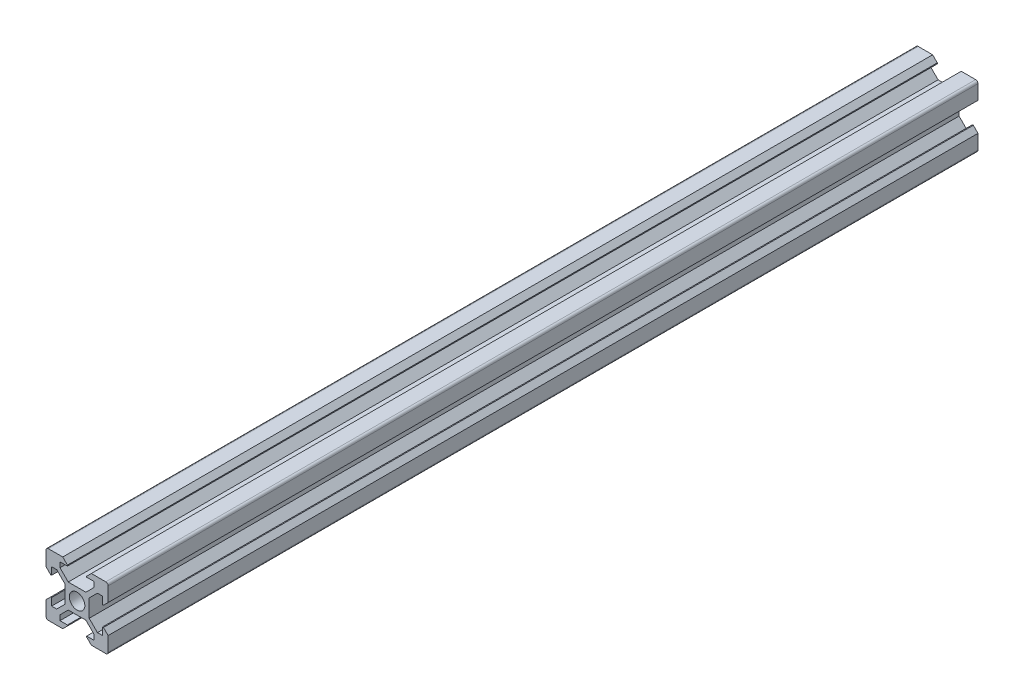
from build123d import *

# Parameters (mm, degrees)
CROQUIS1_R              = 2.5
SALIENTE_EXTRUIR1_DEPTH = 326
SKETCH2_W               = 139.582587955
SKETCH2_H               = 242.432915921
CUT_EXTRUDE1_DEPTH      = 47
CUT_EXTRUDE1_DEPTH_BACK = 30


with BuildPart() as part:
    # Croquis1 → Saliente-Extruir1 (new body)
    with BuildSketch(Plane.XY):
        with BuildLine():
            Line((-4.6, 10), (-3.1, 8.5))
            Line((-3.1, 8.5), (-3.1, 8.2))
            Line((-3.1, 8.2), (-5.5, 8.2))
            Line((-5.5, 8.2), (-5.5, 6.560660172))
            Line((-5.5, 6.560660172), (-2.84, 3.900660172))
            Line((-2.84, 3.900660172), (0, 3.900660172))
            Line((0, 3.900660172), (2.84, 3.900660172))
            Line((2.84, 3.900660172), (5.5, 6.560660172))
            Line((5.5, 6.560660172), (5.5, 8.2))
            Line((5.5, 8.2), (3.1, 8.2))
            Line((3.1, 8.2), (3.1, 8.5))
            Line((3.1, 8.5), (4.6, 10))
            Line((4.6, 10), (9.25, 10))
            ThreePointArc((9.25, 10), (9.780330086, 9.780330086), (10, 9.25))
            Line((10, 9.25), (10, 4.6))
            Line((10, 4.6), (8.5, 3.1))
            Line((8.5, 3.1), (8.2, 3.1))
            Line((8.2, 3.1), (8.2, 5.5))
            Line((8.2, 5.5), (6.560660172, 5.5))
            Line((6.560660172, 5.5), (3.900660172, 2.84))
            Line((3.900660172, 2.84), (3.900660172, 0))
            Line((3.900660172, 0), (3.900660172, -2.84))
            Line((3.900660172, -2.84), (6.560660172, -5.5))
            Line((6.560660172, -5.5), (8.2, -5.5))
            Line((8.2, -5.5), (8.2, -3.1))
            Line((8.2, -3.1), (8.5, -3.1))
            Line((8.5, -3.1), (10, -4.6))
            Line((10, -4.6), (10, -9.25))
            ThreePointArc((10, -9.25), (9.780330086, -9.780330086), (9.25, -10))
            Line((9.25, -10), (4.6, -10))
            Line((4.6, -10), (3.1, -8.5))
            Line((3.1, -8.5), (3.1, -8.2))
            Line((3.1, -8.2), (5.5, -8.2))
            Line((5.5, -8.2), (5.5, -6.560660172))
            Line((5.5, -6.560660172), (2.84, -3.900660172))
            Line((2.84, -3.900660172), (0, -3.900660172))
            Line((0, -3.900660172), (-2.84, -3.900660172))
            Line((-2.84, -3.900660172), (-5.5, -6.560660172))
            Line((-5.5, -6.560660172), (-5.5, -8.2))
            Line((-5.5, -8.2), (-3.1, -8.2))
            Line((-3.1, -8.2), (-3.1, -8.5))
            Line((-3.1, -8.5), (-4.6, -10))
            Line((-4.6, -10), (-9.25, -10))
            ThreePointArc((-9.25, -10), (-9.780330086, -9.780330086), (-10, -9.25))
            Line((-10, -9.25), (-10, -4.6))
            Line((-10, -4.6), (-8.5, -3.1))
            Line((-8.5, -3.1), (-8.2, -3.1))
            Line((-8.2, -3.1), (-8.2, -5.5))
            Line((-8.2, -5.5), (-6.560660172, -5.5))
            Line((-6.560660172, -5.5), (-3.900660172, -2.84))
            Line((-3.900660172, -2.84), (-3.900660172, 0))
            Line((-3.900660172, 0), (-3.900660172, 2.84))
            Line((-3.900660172, 2.84), (-6.560660172, 5.5))
            Line((-6.560660172, 5.5), (-8.2, 5.5))
            Line((-8.2, 5.5), (-8.2, 3.1))
            Line((-8.2, 3.1), (-8.5, 3.1))
            Line((-8.5, 3.1), (-10, 4.6))
            Line((-10, 4.6), (-10, 9.25))
            ThreePointArc((-10, 9.25), (-9.780330086, 9.780330086), (-9.25, 10))
            Line((-9.25, 10), (-4.6, 10))
        make_face()
        Circle(CROQUIS1_R, mode=Mode.SUBTRACT)
    extrude(amount=SALIENTE_EXTRUIR1_DEPTH)

    # Sketch2 → Cut-Extrude1 (cut, two sides)
    with BuildSketch(Plane(origin=(0, 0, 0), x_dir=(1, 0, 0), z_dir=(0, 1, 0))) as cut_extrude1_sk:
        with Locations((12.355396541, -401.216457961)):
            Rectangle(SKETCH2_W, SKETCH2_H)
    extrude(amount=CUT_EXTRUDE1_DEPTH, mode=Mode.SUBTRACT)
    extrude(cut_extrude1_sk.sketch, amount=-CUT_EXTRUDE1_DEPTH_BACK, mode=Mode.SUBTRACT)


solid = part.part
